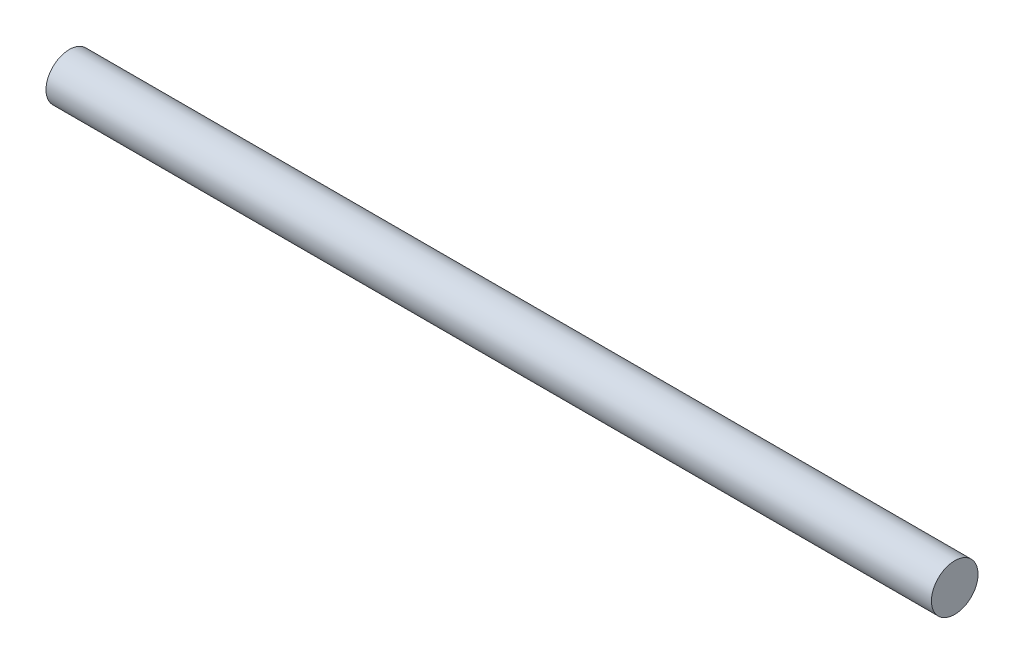
from build123d import *

# Parameters (mm, degrees)
SKETCH1_W = 95
SKETCH1_H = 2.5


with BuildPart() as part:
    # Sketch1 → Revolve1 (revolve)
    with BuildSketch(Plane.XY):
        with Locations((0, 1.25)):
            Rectangle(SKETCH1_W, SKETCH1_H)
    revolve(axis=Axis((-9.135507564, 0, 0), (1, 0, 0)))


solid = part.part
